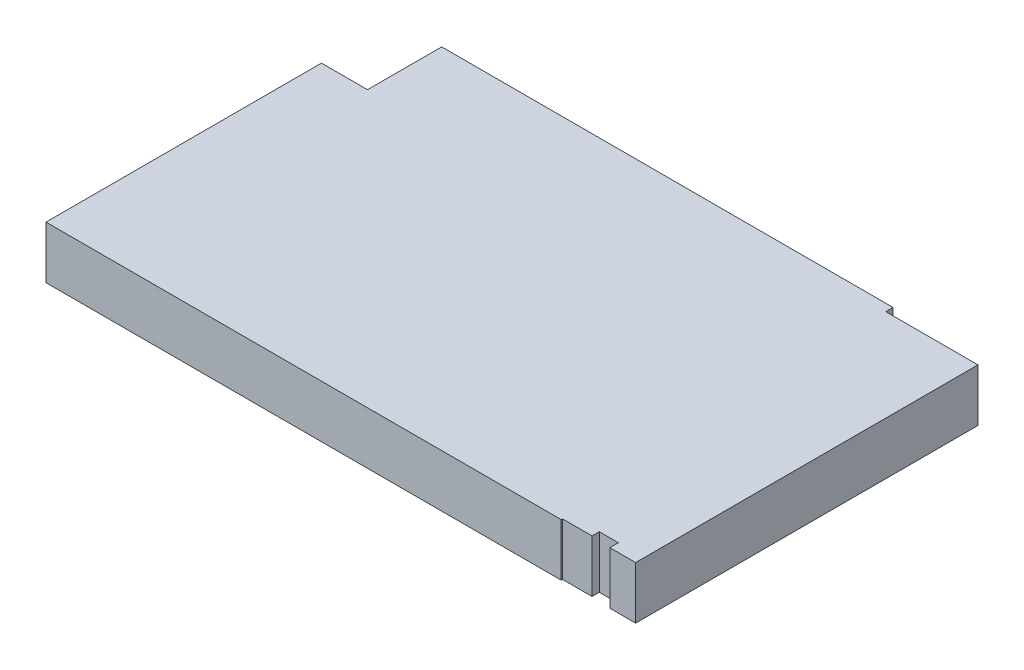
from build123d import *

# Parameters (mm, degrees)
BOSS_EXTRUDE1_DEPTH = 14.47


with BuildPart() as part:
    # Sketch1 → Boss-Extrude1 (new body)
    with BuildSketch(Plane(origin=(0, 0, 0), x_dir=(1, 0, 0), z_dir=(0, 1, 0))):
        Polygon((0, 0), (0, 75.95), (12.7, 75.95), (12.7, 96.4), (137.15, 96.4), (137.15, 94.4), (162.57, 94.4), (162.57, 0), (155.45, 0), (155.45, 2.35), (150.2, 2.35), (150.2, 0.35), (142.05, 0.35), (142.05, 0), align=None)
    extrude(amount=BOSS_EXTRUDE1_DEPTH)


solid = part.part
